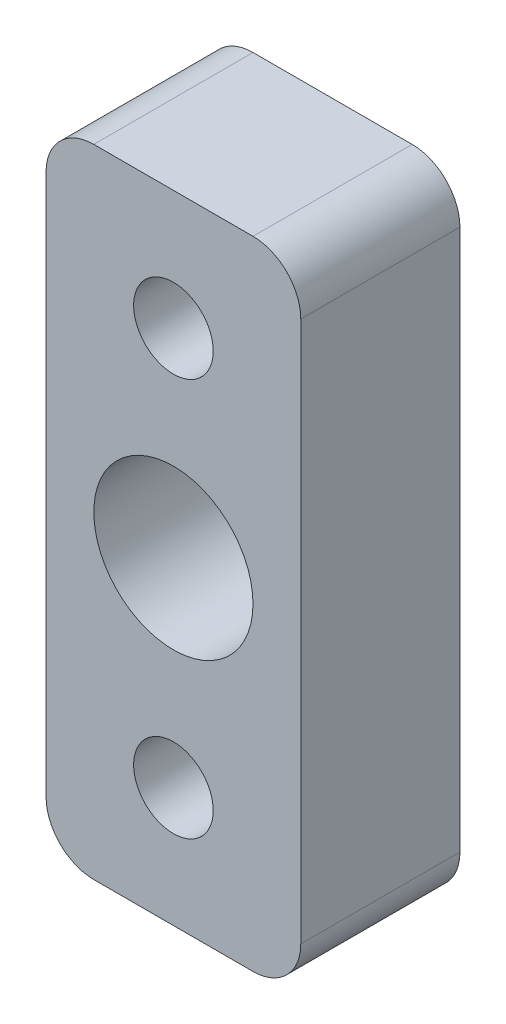
from build123d import *

# Parameters (mm, degrees)
SKETCH_1_W      = 16
SKETCH_1_H      = 40
SKETCH_1_R      = 2.5
SKETCH_1_R_2    = 5
EXTRUDE_1_DEPTH = 10
FILLET_1_R      = 3


with BuildPart() as part:
    # 草图1 → 凸台-拉伸1 (new body)
    with BuildSketch(Plane.XY):
        with Locations((0, 12.5)):
            Rectangle(SKETCH_1_W, SKETCH_1_H)
        with Locations((0, 25)):
            Circle(SKETCH_1_R, mode=Mode.SUBTRACT)
        Circle(SKETCH_1_R, mode=Mode.SUBTRACT)
        with Locations((0, 12.5)):
            Circle(SKETCH_1_R_2, mode=Mode.SUBTRACT)
    extrude(amount=EXTRUDE_1_DEPTH)

    # 圆角1
    fillet_1_edges = [part.edges().sort_by_distance(p)[0] for p in [
        (8, -7.5, 5),
        (-8, -7.5, 5),
        (-8, 32.5, 5),
        (8, 32.5, 5),
    ]]
    fillet(fillet_1_edges, radius=FILLET_1_R)


solid = part.part
